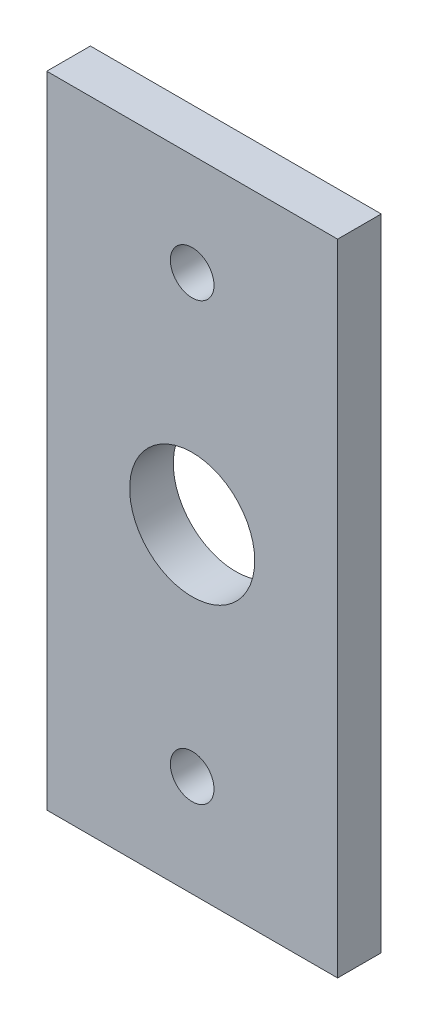
from build123d import *

# Parameters (mm, degrees)
SKETCH1_W           = 20
SKETCH1_H           = 44
SKETCH1_R           = 1.5
SKETCH1_R_2         = 4.3
BOSS_EXTRUDE1_DEPTH = 3


with BuildPart() as part:
    # Sketch1 → Boss-Extrude1 (new body)
    with BuildSketch(Plane.XY):
        with Locations((10, -22)):
            Rectangle(SKETCH1_W, SKETCH1_H)
        with Locations((10, -7)):
            Circle(SKETCH1_R, mode=Mode.SUBTRACT)
        with Locations((10, -37)):
            Circle(SKETCH1_R, mode=Mode.SUBTRACT)
        with Locations((10, -22)):
            Circle(SKETCH1_R_2, mode=Mode.SUBTRACT)
    extrude(amount=BOSS_EXTRUDE1_DEPTH)


solid = part.part
